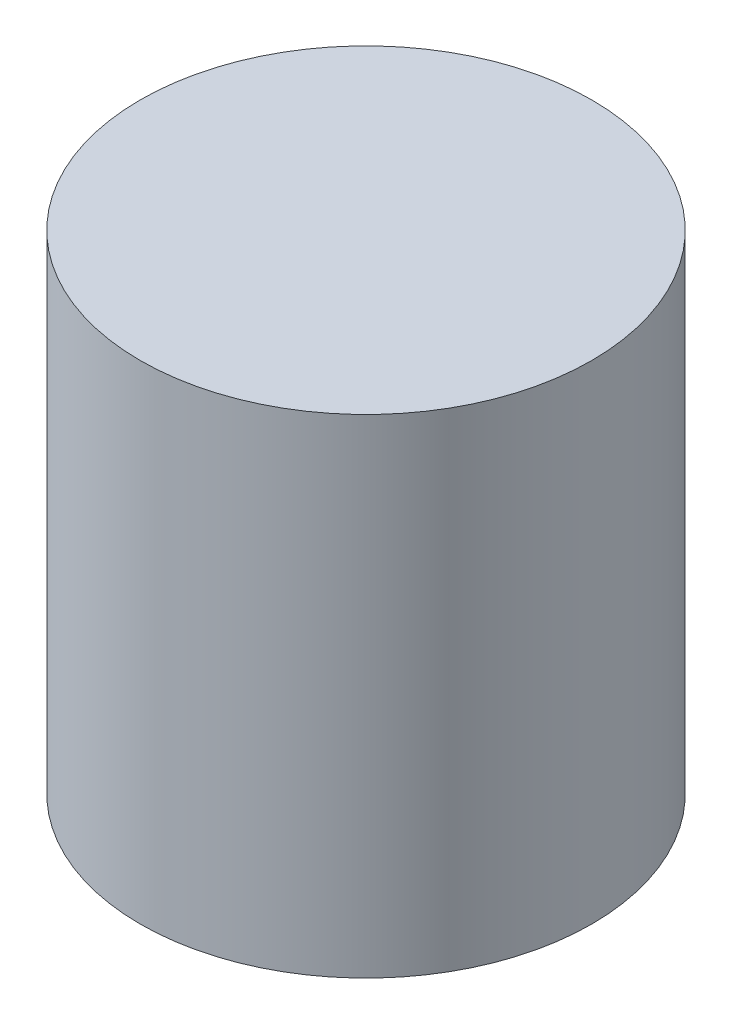
from build123d import *

# Parameters (mm, degrees)
SKETCH1_R           = 18.5
BOSS_EXTRUDE1_DEPTH = 40


with BuildPart() as part:
    # Sketch1 → Boss-Extrude1 (new body)
    with BuildSketch(Plane(origin=(0, 0, 0), x_dir=(1, 0, 0), z_dir=(0, 1, 0))):
        Circle(SKETCH1_R)
    extrude(amount=BOSS_EXTRUDE1_DEPTH)


solid = part.part
